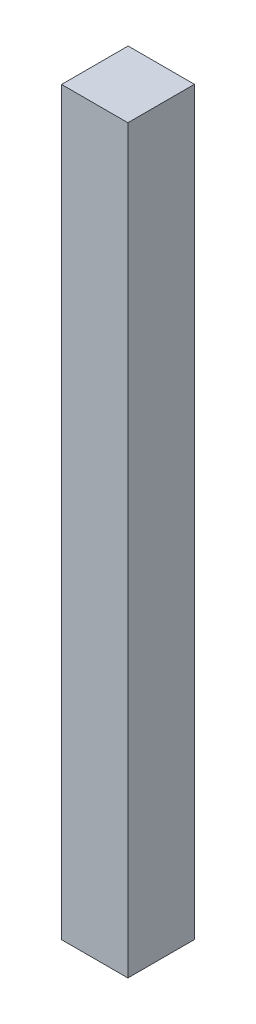
from build123d import *

# Parameters (mm, degrees)
SKETCH1_W           = 34.798
SKETCH1_H           = 34.925
BOSS_EXTRUDE1_DEPTH = 388.62


with BuildPart() as part:
    # Sketch1 → Boss-Extrude1 (new body)
    with BuildSketch(Plane(origin=(0, 0, 0), x_dir=(1, 0, 0), z_dir=(0, 1, 0))):
        Rectangle(SKETCH1_W, SKETCH1_H)
    extrude(amount=BOSS_EXTRUDE1_DEPTH)


solid = part.part
